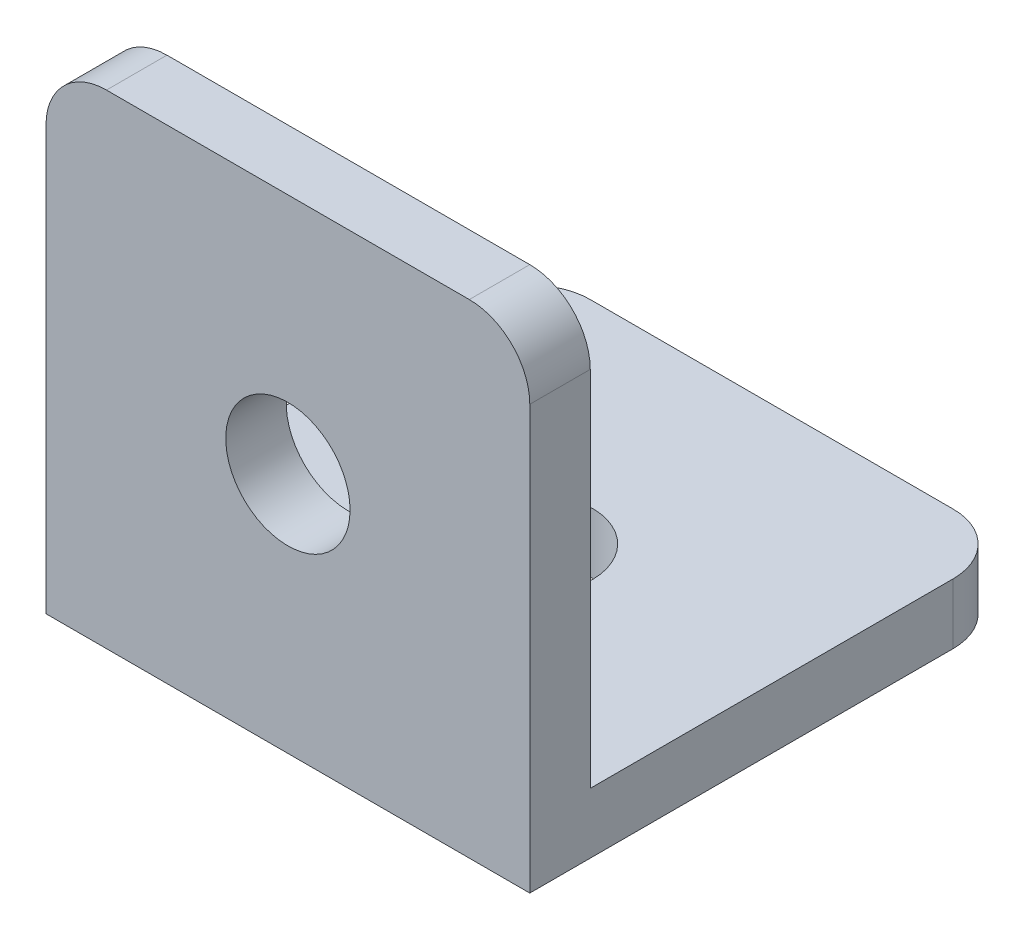
from build123d import *

# Parameters (mm, degrees)
SKETCH1_W           = 25.4
SKETCH1_H           = 25.4
SKETCH1_R           = 3.2639
BOSS_EXTRUDE1_DEPTH = 3.175
SKETCH2_W           = 25.4
SKETCH2_H           = 3.175
BOSS_EXTRUDE2_DEPTH = 22.225
SKETCH3_R           = 3.2639
CUT_EXTRUDE1_DEPTH  = 3.175
FILLET1_R           = 3.175


with BuildPart() as part:
    # Sketch1 → Boss-Extrude1 (new body)
    with BuildSketch(Plane(origin=(0, 0, 0), x_dir=(1, 0, 0), z_dir=(0, 1, 0))):
        with Locations((12.7, 12.7)):
            Rectangle(SKETCH1_W, SKETCH1_H)
        with Locations((12.7, 12.7)):
            Circle(SKETCH1_R, mode=Mode.SUBTRACT)
    extrude(amount=BOSS_EXTRUDE1_DEPTH)

    # Sketch2 → Boss-Extrude2 (add)
    with BuildSketch(Plane(origin=(0, 3.175, 0), x_dir=(1, 0, 0), z_dir=(0, 1, 0))):
        with Locations((12.7, 1.5875)):
            Rectangle(SKETCH2_W, SKETCH2_H)
    extrude(amount=BOSS_EXTRUDE2_DEPTH)

    # Sketch3 → Cut-Extrude1 (cut)
    with BuildSketch(Plane.XY):
        with Locations((12.7, 12.7)):
            Circle(SKETCH3_R)
    extrude(amount=-CUT_EXTRUDE1_DEPTH, mode=Mode.SUBTRACT)

    # Fillet1
    fillet1_edges = [part.edges().sort_by_distance(p)[0] for p in [
        (0, 25.4, -1.5875),
        (25.4, 25.4, -1.5875),
        (0, 1.5875, -25.4),
        (25.4, 1.5875, -25.4),
    ]]
    fillet(fillet1_edges, radius=FILLET1_R)


solid = part.part
